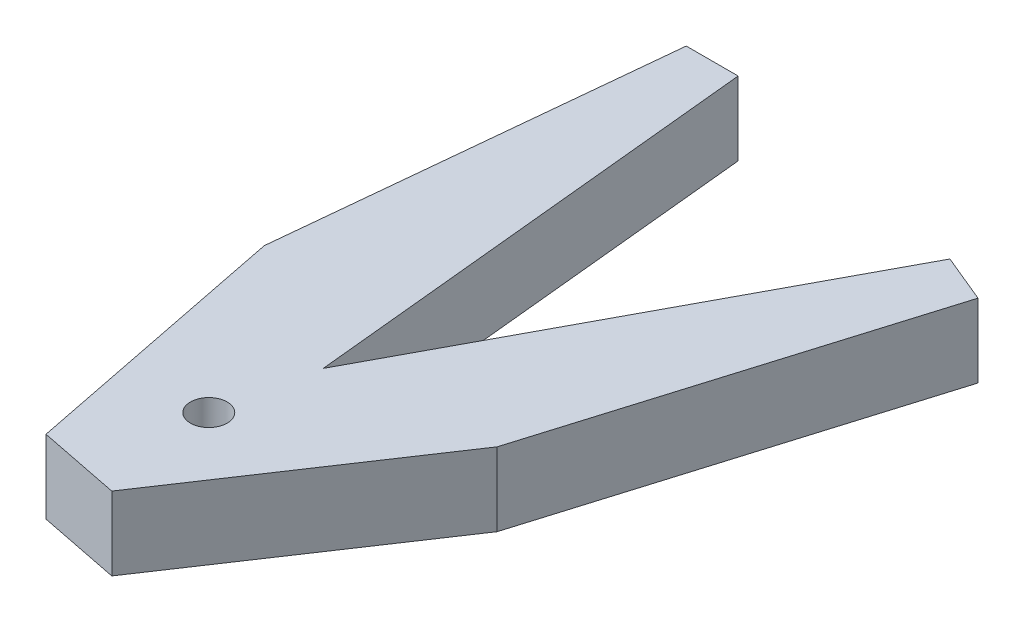
from build123d import *

# Parameters (mm, degrees)
ESQUISSE1_R        = 4.25
BOSS_EXTRU_1_DEPTH = 17


with BuildPart() as part:
    # Esquisse1 → Boss.-Extru.1 (new body)
    with BuildSketch(Plane(origin=(0, 0, 0), x_dir=(1, 0, 0), z_dir=(0, 1, 0))):
        Polygon((-6, 189.905239528), (0, 189.905239528), (6, 189.905239528), (16.582677371, 83.366748834), (67.130311691, 177.74566451), (72.673588887, 175.449563916), (78.216866082, 173.153463322), (52.395009204, 87.774425431), (42.899827823, 73.563882257), (31.788423162, 56.934490011), (16.702518765, 34.356838555), (-2.283322325, 38.133357153), (-7.580787473, 64.765512901), (-11.482593913, 84.381218509), (-14.816858212, 101.143697095), align=None)
        with Locations(Location((12.193145126, 61.299080025, 0), (0, 0, 270))):  # turned: the seam where the file's is
            Circle(ESQUISSE1_R, mode=Mode.SUBTRACT)
    extrude(amount=BOSS_EXTRU_1_DEPTH)


solid = part.part
